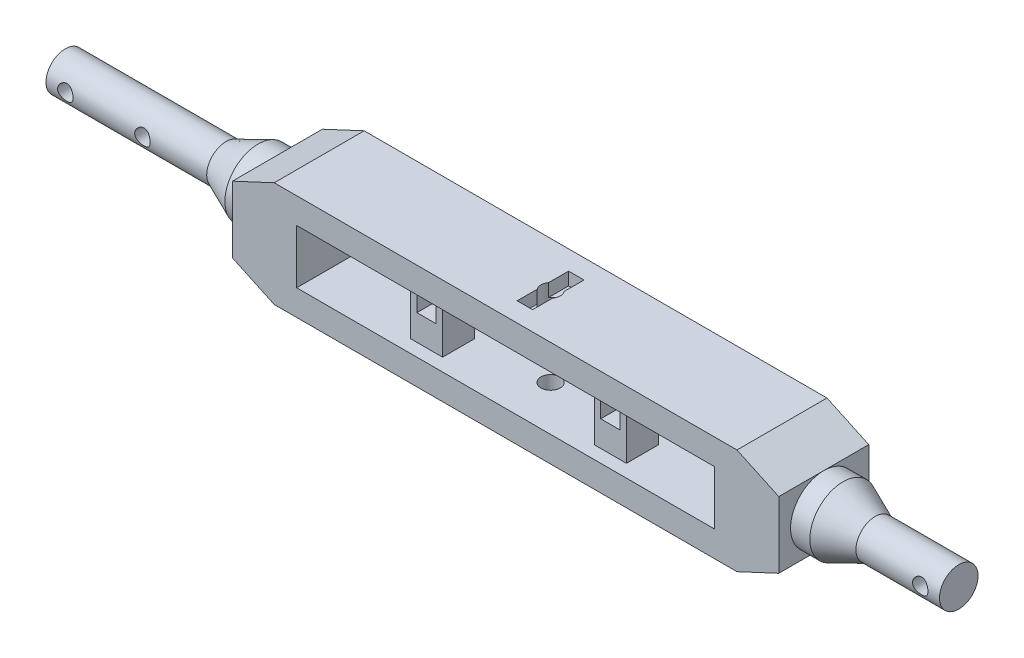
from build123d import *

# Parameters (mm, degrees)
SKETCH1_W                   = 32.5
SKETCH1_H                   = 4.2
BASEFORM_DEPTH              = 7
SKETCH2_R                   = 0.75
HUMERUSAXLEHOLE1_DEPTH      = 2
HUMERUSAXLELOCK_DEPTH       = 1
SKETCH6_R                   = 1.5
AXLEEXTENSION_DEPTH         = 6
SKETCH7_R                   = 0.6
SCREWHOLES_DEPTH            = 54.273445543
SCREWHOLES_DEPTH_BACK       = 54.273445543
SKETCH8_W                   = 2.5
SKETCH8_H                   = 2.5
HUMERUSTUBEHOLDERBASE_DEPTH = 4.2
SKETCH13_W                  = 1.5
SKETCH13_H                  = 1.5
TUBECLIPENTRANCE_DEPTH      = 2
SKETCH14_W                  = 1.5
SKETCH14_H                  = 1.5
CABLECLIPLOCKSLOT_DEPTH     = 0.7
SKETCH15_W                  = 1.5
SKETCH15_H                  = 0.2
TUBECLIPLOCKCLEARANCE_DEPTH = 2
SKETCH12_R                  = 0.75
HUMERUSAXLEHOLE2_DEPTH      = 54.818584249


with BuildPart() as part:
    # Sketch1 → BaseForm (new body)
    with BuildSketch(Plane.XY):
        Polygon((0, -2.584500111), (0, 2.584500111), (3.25, 4.1), (39.25, 4.1), (42.5, 2.584500111), (42.5, -2.584500111), (39.25, -4.1), (3.25, -4.1), align=None)
        with Locations((21.25, 0)):
            Rectangle(SKETCH1_W, SKETCH1_H, mode=Mode.SUBTRACT)
    extrude(amount=BASEFORM_DEPTH)

    # Sketch2 → HumerusAxleHole1 (cut)
    with BuildSketch(Plane(origin=(0, 4.1, 0), x_dir=(1, 0, 0), z_dir=(0, 1, 0))):
        with Locations(Location((21.25, -3.5, 0), (0, 0, 270))):
            Circle(SKETCH2_R)
    extrude(amount=-HUMERUSAXLEHOLE1_DEPTH, mode=Mode.SUBTRACT)

    # Sketch2_4 → HumerusAxleLock (cut)
    with BuildSketch(Plane(origin=(0, 4.1, 0), x_dir=(1, 0, 0), z_dir=(0, 1, 0))):
        with BuildLine():
            ThreePointArc((20.65, -3.05), (21.25, -2.75), (21.85, -3.05))
            Line((21.85, -3.05), (21.85, -1.5))
            Line((21.85, -1.5), (20.65, -1.5))
            Line((20.65, -1.5), (20.65, -3.05))
        make_face()
        with BuildLine():
            Line((21.85, -5.5), (21.85, -3.95))
            ThreePointArc((21.85, -3.95), (21.25, -4.25), (20.65, -3.95))
            Line((20.65, -3.95), (20.65, -5.5))
            Line((20.65, -5.5), (21.85, -5.5))
        make_face()
    extrude(amount=-HUMERUSAXLELOCK_DEPTH, mode=Mode.SUBTRACT)

    # Sketch5 → Axle (revolve)
    with BuildSketch(Plane.XY.offset(3.5), mode=Mode.PRIVATE) as axle_sk:
        Polygon((53, 0), (53, 1.5), (46.5, 1.5), (44, 2.584500111), (42.5, 2.584500111), (42.5, 0), align=None)
    axle = revolve(axle_sk.sketch.rotate(Axis((42.5, 0, 3.5), (1, 0, 0)), 90), axis=Axis((42.5, 0, 3.5), (1, 0, 0)))

    # Axle2: Axle across plane
    add(axle.mirror(Plane.ZY.offset(-21.25)))

    # Sketch6 → AxleExtension (add)
    with BuildSketch(Plane.ZY.offset(10.5)):
        with Locations((3.5, 0)):
            Circle(SKETCH6_R)
    extrude(amount=AXLEEXTENSION_DEPTH)

    # Sketch7 → ScrewHoles (cut, two sides)
    with BuildSketch(Plane.XY.offset(3.5)) as screwholes_sk:
        with Locations((-9, 0)):
            Circle(SKETCH7_R)
        with Locations((-15, 0)):
            Circle(SKETCH7_R)
        with Locations((51.5, 0)):
            Circle(SKETCH7_R)
    extrude(amount=SCREWHOLES_DEPTH, mode=Mode.SUBTRACT)
    extrude(screwholes_sk.sketch, amount=-SCREWHOLES_DEPTH_BACK, mode=Mode.SUBTRACT)

    # Sketch8 → HumerusTubeHolderBase (add)
    with BuildSketch(Plane(origin=(0, 2.1, 0), x_dir=(1, 0, 0), z_dir=(0, 1, 0))):
        with Locations((14.1, -4.75)):
            Rectangle(SKETCH8_W, SKETCH8_H)
    humerustubeholderbase = extrude(amount=-HUMERUSTUBEHOLDERBASE_DEPTH)

    # Sketch13 → TubeClipEntrance (cut)
    with BuildSketch(Plane.XY.offset(6)):
        with Locations((14.1, 0.65)):
            Rectangle(SKETCH13_W, SKETCH13_H)
    tubeclipentrance = extrude(amount=-TUBECLIPENTRANCE_DEPTH, mode=Mode.SUBTRACT)

    # Sketch14 → CableClipLockSlot (cut)
    with BuildSketch(Plane.XZ.offset(-1.4)):
        with Locations((14.1, 4.75)):
            Rectangle(SKETCH14_W, SKETCH14_H)
    cablecliplockslot = extrude(amount=-CABLECLIPLOCKSLOT_DEPTH, mode=Mode.SUBTRACT)

    # Sketch15 → TubeClipLockClearance (cut)
    with BuildSketch(Plane.XY.offset(6)):
        with Locations((14.1, 1.5)):
            Rectangle(SKETCH15_W, SKETCH15_H)
    tubecliplockclearance = extrude(amount=-TUBECLIPLOCKCLEARANCE_DEPTH, mode=Mode.SUBTRACT)

    # Sketch12 → HumerusAxleHole2 (cut, through all)
    with BuildSketch(Plane(origin=(0, -2.1, 0), x_dir=(1, 0, 0), z_dir=(0, 1, 0))):
        with Locations(Location((21.25, -3.5, 0), (0, 0, 323.130102354))):
            Circle(SKETCH12_R)
    extrude(amount=-HUMERUSAXLEHOLE2_DEPTH, mode=Mode.SUBTRACT)

    # TubeClipSlot2: HumerusTubeHolderBase, TubeClipEntrance, CableClipLockSlot, TubeClipLockClearance across plane
    add(humerustubeholderbase.mirror(Plane(origin=(21.25, 0, 0), x_dir=(0, 0, 1), z_dir=(1, 0, 0))))
    add(tubeclipentrance.mirror(Plane(origin=(21.25, 0, 0), x_dir=(0, 0, 1), z_dir=(1, 0, 0))), mode=Mode.SUBTRACT)
    add(cablecliplockslot.mirror(Plane(origin=(21.25, 0, 0), x_dir=(0, 0, 1), z_dir=(1, 0, 0))), mode=Mode.SUBTRACT)
    add(tubecliplockclearance.mirror(Plane(origin=(21.25, 0, 0), x_dir=(0, 0, 1), z_dir=(1, 0, 0))), mode=Mode.SUBTRACT)


solid = part.part
